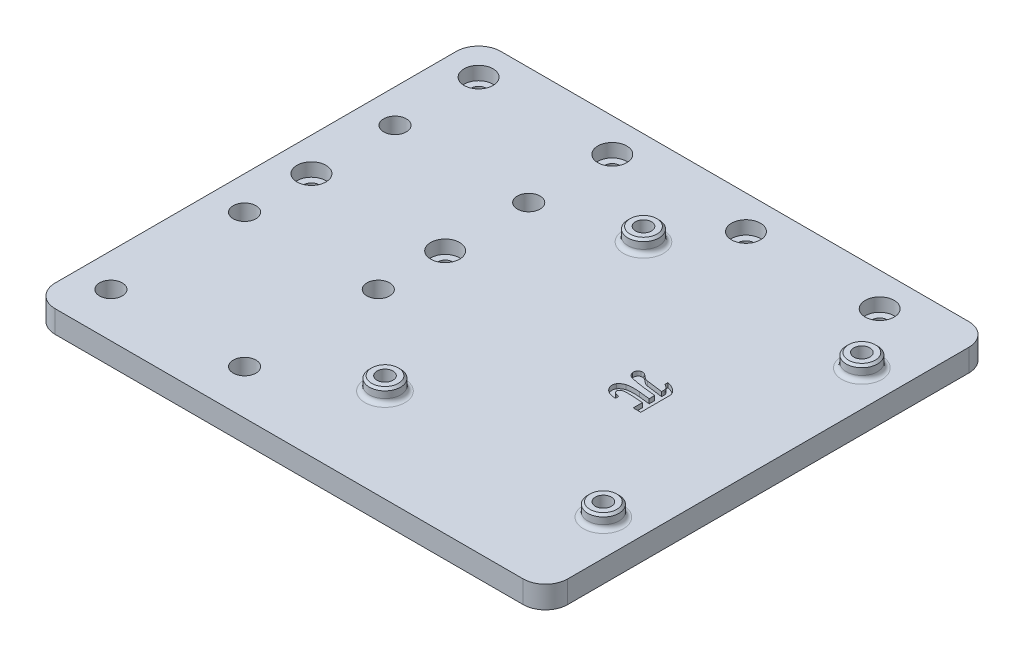
from build123d import *

# Parameters (mm, degrees)
SKETCH1_W                      = 65
SKETCH1_H                      = 100
BOSS_EXTRUDE1_DEPTH            = 5
SKETCH2_R                      = 3.5
BOSS_EXTRUDE2_DEPTH            = 3
F_3_6_3_6_DIAMETER_HOLE1_D     = 3.6
CBORE_FOR_M3_SHCS1_D           = 3.4
CBORE_FOR_M3_SHCS1_CBORE_D     = 6.5
CBORE_FOR_M3_SHCS1_CBORE_DEPTH = 3
SKETCH9_W                      = 100
SKETCH9_H                      = 5
BOSS_EXTRUDE3_DEPTH            = 50
CBORE_FOR_M3_SHCS2_D           = 3.4
CBORE_FOR_M3_SHCS2_CBORE_D     = 6.5
CBORE_FOR_M3_SHCS2_CBORE_DEPTH = 3
F_5_1_5_1_DIAMETER_HOLE1_D     = 5.1
CUT_EXTRUDE1_DEPTH             = 1
FILLET1_R                      = 1
FILLET2_R                      = 5
CHAMFER2_SIZE                  = 0.5


with BuildPart() as part:
    # Sketch1 → Boss-Extrude1 (new body)
    with BuildSketch(Plane(origin=(0, 0, 0), x_dir=(1, 0, 0), z_dir=(0, 1, 0))):
        with Locations((32.5, -50)):
            Rectangle(SKETCH1_W, SKETCH1_H)
    extrude(amount=BOSS_EXTRUDE1_DEPTH)

    # Sketch2 → Boss-Extrude2 (add)
    with BuildSketch(Plane(origin=(0, 5, 0), x_dir=(1, 0, 0), z_dir=(0, 1, 0))):
        with Locations(Location((8, -21, 0), (0, 0, 270))):
            Circle(SKETCH2_R)
        with Locations(Location((57, -21, 0), (0, 0, 270))):
            Circle(SKETCH2_R)
        with Locations(Location((57, -79, 0), (0, 0, 270))):
            Circle(SKETCH2_R)
        with Locations(Location((8, -79, 0), (0, 0, 270))):
            Circle(SKETCH2_R)
    extrude(amount=BOSS_EXTRUDE2_DEPTH)

    # Ø3.6 (3.6) Diameter Hole1 (through all)
    with Locations(Plane(origin=(0, 8, 0), x_dir=(1, 0, 0), z_dir=(0, 1, 0))):
        with Locations((8, -21), (57, -21), (57, -79), (8, -79)):
            Hole(F_3_6_3_6_DIAMETER_HOLE1_D / 2)

    # CBORE for M3 SHCS1 (through all)
    with Locations(Plane(origin=(0, 5, 0), x_dir=(1, 0, 0), z_dir=(0, 1, 0))):
        with Locations((17.5, -7.5), (47.5, -7.5)):
            CounterBoreHole(CBORE_FOR_M3_SHCS1_D / 2, CBORE_FOR_M3_SHCS1_CBORE_D / 2, CBORE_FOR_M3_SHCS1_CBORE_DEPTH)

    # Sketch9 → Boss-Extrude3 (add)
    with BuildSketch(Plane.ZY):
        with Locations((50, 2.5)):
            Rectangle(SKETCH9_W, SKETCH9_H)
    extrude(amount=BOSS_EXTRUDE3_DEPTH)

    # CBORE for M3 SHCS2 (through all)
    with Locations(Plane(origin=(0, 5, 0), x_dir=(1, 0, 0), z_dir=(0, 1, 0))):
        with Locations((-42.5, -45), (-12.5, -7.5), (-42.5, -7.5), (-12.5, -45)):
            CounterBoreHole(CBORE_FOR_M3_SHCS2_D / 2, CBORE_FOR_M3_SHCS2_CBORE_D / 2, CBORE_FOR_M3_SHCS2_CBORE_DEPTH)

    # Ø5.1 (5.1) Diameter Hole1 (through all)
    with Locations(Plane(origin=(0, 5, 0), x_dir=(1, 0, 0), z_dir=(0, 1, 0))):
        with Locations((-12.5, -26.25), (-12.5, -60), (-12.5, -90), (-42.5, -90), (-42.5, -60), (-42.5, -26.25)):
            Hole(F_5_1_5_1_DIAMETER_HOLE1_D / 2)

    # Sketch16 → Cut-Extrude1 (cut)
    with BuildSketch(Plane(origin=(0, 5, 0), x_dir=(1, 0, 0), z_dir=(0, 1, 0))):
        with BuildLine():
            Line((39.126262207, -50.847545166), (39.126262207, -49.597897606))
            add(Edge.make_bspline(
                [(39.126262207, -49.597897606), (38.887061603, -49.575713781), (38.426953933, -49.5330427), (37.765335099, -49.467029699), (37.16050318, -49.395654418), (36.608878249, -49.329176979), (36.103389832, -49.260432621), (35.637684233, -49.194155672), (35.207796553, -49.125451167), (34.693851603, -49.042468377), (34.106849427, -48.930569543), (33.65316464, -48.833024779), (33.43663372, -48.786469421)],
                knots=[0, 0, 0, 0, 1.253096053, 2.41035807, 3.468180285, 4.429891672, 5.308555075, 6.129167563, 6.883542428, 7.579384342, 8.844708592, 10, 10, 10, 10], degree=3))
            add(Edge.make_bspline(
                [(33.43663372, -48.786469421), (33.362346649, -48.767894411), (33.217288497, -48.731623541), (33.012809199, -48.653717957), (32.825678299, -48.562470211), (32.654731085, -48.453628715), (32.502165181, -48.313171441), (32.378215441, -48.129778401), (32.270782782, -47.910183348), (32.22072951, -47.746398482), (32.194209557, -47.659619598)],
                knots=[0, 0, 0, 0, 1.028706086, 2.008723763, 2.935244992, 3.824118955, 4.724963072, 5.700873389, 6.781843246, 8, 8, 8, 8], degree=3))
            add(Edge.make_bspline(
                [(32.194209557, -47.659619598), (32.184050249, -47.593155924), (32.163986257, -47.461894353), (32.185456965, -47.261992825), (32.24760698, -47.068817641), (32.345988654, -46.886281707), (32.470276431, -46.723283517), (32.612903387, -46.590894898), (32.770825068, -46.49396615), (32.885825633, -46.461994139), (32.943034973, -46.44608902)],
                knots=[0, 0, 0, 0, 1.027404461, 2.029059083, 3.048769739, 4.122307651, 5.19302046, 6.17728816, 7.093255398, 8, 8, 8, 8], degree=3))
            add(Edge.make_bspline(
                [(32.943034973, -46.44608902), (33.019790611, -46.432729059), (33.159183567, -46.408466548), (33.358775166, -46.415044291), (33.530189985, -46.45624418), (33.682659012, -46.516761006), (33.820245014, -46.588705021), (33.94106644, -46.670397622), (34.053969979, -46.753634053), (34.125488835, -46.811784665), (34.161381149, -46.840968018)],
                knots=[0, 0, 0, 0, 1.397360562, 2.537692669, 3.559369145, 4.550448304, 5.47954959, 6.34367758, 7.168761249, 8, 8, 8, 8], degree=3))
            add(Edge.make_bspline(
                [(34.161381149, -46.840968018), (34.171740761, -46.84988817), (34.20290871, -46.876725361), (34.270587507, -46.926391538), (34.365875235, -47.009106142), (34.490280901, -47.108420261), (34.623007569, -47.217425956), (34.758849499, -47.313547894), (34.885293124, -47.395630136), (35.04302611, -47.483660165), (35.248195948, -47.563686604), (35.419904702, -47.590557351), (35.50734066, -47.604240227)],
                knots=[0, 0, 0, 0, 0.26063328, 0.784141858, 1.599335041, 2.665418653, 3.819900223, 4.873162956, 5.836886495, 6.693141337, 8.316111744, 10, 10, 10, 10], degree=3))
            Line((35.50734066, -47.604240227), (39.126262207, -48.073760986))
            Line((39.126262207, -48.073760986), (39.126262207, -47.466995697))
            add(Edge.make_bspline(
                [(39.126262207, -47.466995697), (39.120615941, -47.395372643), (39.108842141, -47.246021633), (39.011762919, -47.038358034), (38.893301343, -46.84311371), (38.780591009, -46.744004371), (38.726567612, -46.696500092)],
                knots=[0, 0, 0, 0, 0.957298162, 1.996193101, 3.039551627, 4, 4, 4, 4], degree=3))
            Line((38.726567612, -46.696500092), (38.098132133, -46.282358704))
            Line((38.098132133, -46.282358704), (38.098132133, -45.608175049))
            add(Edge.make_bspline(
                [(38.098132133, -45.608175049), (38.265069197, -45.651305716), (38.590637549, -45.73542113), (39.059543061, -45.904315208), (39.510452961, -46.111726833), (39.782169404, -46.301225336), (39.9208358, -46.397933044)],
                knots=[0, 0, 0, 0, 1.033858386, 2.016278253, 2.987637474, 4, 4, 4, 4], degree=3))
            add(Edge.make_bspline(
                [(39.9208358, -46.397933044), (39.980466774, -46.441596233), (40.101066248, -46.529901979), (40.265647201, -46.68871056), (40.416093013, -46.870100588), (40.556417575, -47.068585687), (40.676744862, -47.287138148), (40.759698519, -47.527310442), (40.812591451, -47.784126696), (40.818378437, -47.961125766), (40.821352539, -48.052090797)],
                knots=[0, 0, 0, 0, 0.904302346, 1.828888262, 2.791608349, 3.786843382, 4.80268608, 5.834756118, 6.887217442, 8, 8, 8, 8], degree=3))
            Line((40.821352539, -48.052090797), (40.821352539, -54.430349731))
            Line((40.821352539, -54.430349731), (39.126262207, -54.430349731))
            Line((39.126262207, -54.430349731), (39.126262207, -52.369273987))
            add(Edge.make_bspline(
                [(39.126262207, -52.369273987), (38.824641017, -52.338588763), (38.212494456, -52.276312453), (37.278571929, -52.215269505), (36.316663871, -52.178581692), (35.66628914, -52.174105191), (35.336386948, -52.171834488)],
                knots=[0, 0, 0, 0, 0.958130554, 1.944546155, 2.957372268, 4, 4, 4, 4], degree=3))
            add(Edge.make_bspline(
                [(35.336386948, -52.171834488), (35.216918961, -52.176632011), (34.979958118, -52.18614774), (34.699390908, -52.267738632), (34.498680733, -52.345822532), (34.376377238, -52.399383952), (34.282754213, -52.45111856), (34.234840863, -52.489924695), (34.214352722, -52.506518517)],
                knots=[0, 0, 0, 0, 1.804721428, 3.579605919, 4.387653081, 5.067635593, 5.601313335, 6, 6, 6, 6], degree=3))
            add(Edge.make_bspline(
                [(34.214352722, -52.506518517), (34.158438507, -52.572803412), (34.054075473, -52.696523165), (33.974254217, -52.882970365), (33.965236632, -53.035635661), (33.99855982, -53.155268657), (34.063359986, -53.281985338), (34.125363446, -53.363077846), (34.158973351, -53.407035255)],
                knots=[0, 0, 0, 0, 1.530222605, 2.85613729, 3.495539136, 4.19786485, 5.023125643, 6, 6, 6, 6], degree=3))
            add(Edge.make_bspline(
                [(34.158973351, -53.407035255), (34.202678445, -53.453603851), (34.288209182, -53.54473845), (34.449483531, -53.638340717), (34.618180335, -53.696546772), (34.801341682, -53.734863252), (35.02056346, -53.757230953), (35.181594158, -53.781052837), (35.27378418, -53.794690857)],
                knots=[0, 0, 0, 0, 0.943448386, 1.846325613, 2.731669575, 3.584362821, 4.617048522, 6, 6, 6, 6], degree=3))
            Line((35.27378418, -53.794690857), (35.27378418, -54.543516273))
            add(Edge.make_bspline(
                [(35.27378418, -54.543516273), (35.145259799, -54.539686724), (34.899665229, -54.532368918), (34.549534649, -54.49381644), (34.23492324, -54.435411311), (33.95485327, -54.352646637), (33.704937688, -54.251951832), (33.47764334, -54.142729191), (33.274451352, -54.017945692), (33.089768771, -53.886609091), (32.927584898, -53.741089605), (32.786131125, -53.584968182), (32.654824603, -53.424803574), (32.58524624, -53.30689432), (32.550563774, -53.248120537)],
                knots=[0, 0, 0, 0, 1.463419428, 2.796417783, 4.006075808, 5.101867847, 6.114868065, 7.071137589, 7.969092879, 8.826327314, 9.648155468, 10.443549341, 11.224161887, 12, 12, 12, 12], degree=3))
            add(Edge.make_bspline(
                [(32.550563774, -53.248120537), (32.520790697, -53.193492864), (32.459254397, -53.080585998), (32.397200219, -52.890384649), (32.348206864, -52.6819503), (32.320086722, -52.457698844), (32.315640727, -52.227756787), (32.34661926, -52.004027153), (32.413206209, -51.79241002), (32.487069025, -51.66662071), (32.524077988, -51.603593979)],
                knots=[0, 0, 0, 0, 0.865492594, 1.788838003, 2.776551332, 3.847715376, 4.932865467, 5.972249091, 6.983995453, 8, 8, 8, 8], degree=3))
            add(Edge.make_bspline(
                [(32.524077988, -51.603593979), (32.599388708, -51.507318221), (32.75324726, -51.310628445), (33.055018494, -51.068656229), (33.409086865, -50.860800161), (33.672452045, -50.758731497), (33.809842529, -50.705485039)],
                knots=[0, 0, 0, 0, 0.918076197, 1.875614441, 2.891765566, 4, 4, 4, 4], degree=3))
            add(Edge.make_bspline(
                [(33.809842529, -50.705485039), (33.898631758, -50.682441773), (34.087470798, -50.633432807), (34.395240763, -50.584968257), (34.740993079, -50.551926433), (35.248657148, -50.532699083), (35.895954097, -50.531314455), (36.413618911, -50.570608952), (36.667899666, -50.589910698)],
                knots=[0, 0, 0, 0, 0.574329406, 1.22149743, 1.948877103, 2.749030755, 4.403100056, 6, 6, 6, 6], degree=3))
            Line((36.667899666, -50.589910698), (39.126262207, -50.847545166))
        make_face()
    extrude(amount=-CUT_EXTRUDE1_DEPTH, mode=Mode.SUBTRACT)

    # Fillet1
    fillet1_edges = [part.edges().sort_by_distance(p)[0] for p in [
        (8, 5, 17.5),
        (57, 5, 17.5),
        (57, 5, 75.5),
        (8, 5, 75.5),
    ]]
    fillet(fillet1_edges, radius=FILLET1_R)

    # Fillet2
    fillet2_edges = [part.edges().sort_by_distance(p)[0] for p in [
        (-50, 2.5, 0),
        (-50, 2.5, 100),
        (65, 2.5, 0),
        (65, 2.5, 100),
    ]]
    fillet(fillet2_edges, radius=FILLET2_R)

    # Chamfer2
    chamfer2_edges = [part.edges().sort_by_distance(p)[0] for p in [
        (8, 8, 17.5),
        (57, 8, 17.5),
        (57, 8, 75.5),
        (8, 8, 75.5),
    ]]
    chamfer(chamfer2_edges, length=CHAMFER2_SIZE)


solid = part.part
